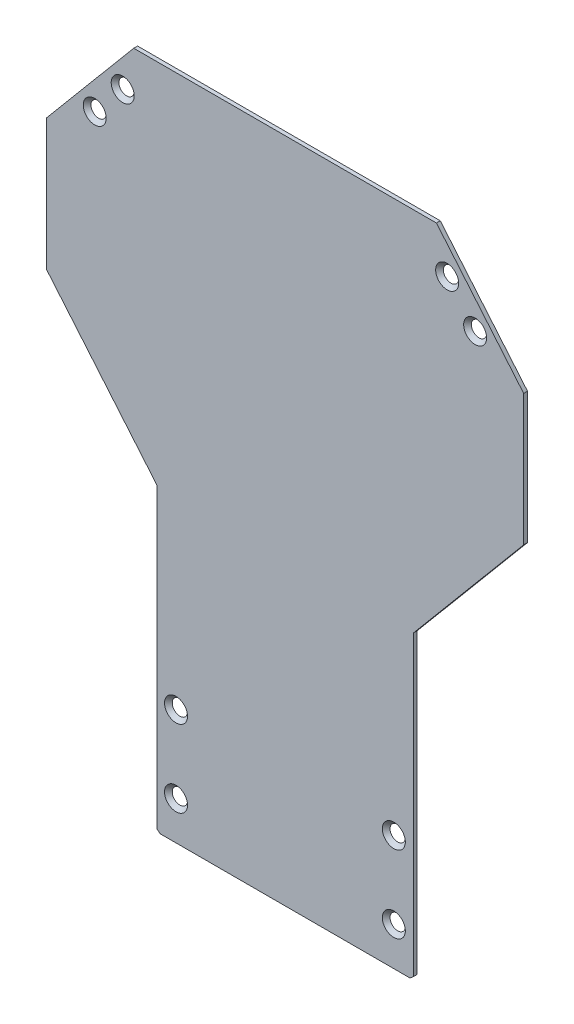
from build123d import *

# Parameters (mm, degrees)
RESSALTO_EXTRUS_O1_DEPTH                     = 1.5
ESCAREADO_PARA_PARAFUSO_ALLEN_SEXTAV_2_COUNT = 2
ESCAREADO_PARA_PARAFUSO_ALLEN_SEXTAV_2_PITCH = 16.970294761
ESCAREADO_PARA_PARAFUSO_ALLEN_SEXTAV_3_COUNT = 2
ESCAREADO_PARA_PARAFUSO_ALLEN_SEXTAV_3_PITCH = 126.454837383
ESCAREADO_PARA_PARAFUSO_ALLEN_SEXTAV_4_COUNT = 2
ESCAREADO_PARA_PARAFUSO_ALLEN_SEXTAV_4_PITCH = 137.976919064
ESCAREADO_PARA_PARAFUSO_ALLEN_SEXTAV_5_COUNT = 2
ESCAREADO_PARA_PARAFUSO_ALLEN_SEXTAV_5_PITCH = 225.316554427
ESCAREADO_PARA_PARAFUSO_ALLEN_SEXTAV_6_COUNT = 2
ESCAREADO_PARA_PARAFUSO_ALLEN_SEXTAV_6_PITCH = 252.205372066
ESCAREADO_PARA_PARAFUSO_ALLEN_SEXTAV_7_COUNT = 2
ESCAREADO_PARA_PARAFUSO_ALLEN_SEXTAV_7_PITCH = 229.941146022
ESCAREADO_PARA_PARAFUSO_ALLEN_SEXTAV_8_COUNT = 2
ESCAREADO_PARA_PARAFUSO_ALLEN_SEXTAV_8_PITCH = 200.082309648


with BuildPart() as part:
    # Esboço1 → Ressalto-extrusão1 (new body)
    with BuildSketch(Plane.XY):
        Polygon((59.050720106, 130.399321825), (-58.939675618, 130.399321825), (-92.944477756, 89.873976712), (-92.944477756, 38.765530101), (-49.944477756, -12.47987438), (-49.944477756, -128.492963544), (-48.624354865, -129.600678175), (48.735399354, -129.600678175), (50.055522244, -128.492963544), (50.055522244, -12.47987438), (93.055522244, 38.765530101), (93.055522244, 89.873976712), align=None)
    extrude(amount=RESSALTO_EXTRUS_O1_DEPTH)

    # Esboço4 → Escareado para parafuso Allen sextavado escareado de M41 (revolve, cut)
    with BuildSketch(Plane(origin=(-63.227418691, 114.399321825, 1.5), x_dir=(0, -1, 0), z_dir=(1, 0, 0))):
        Polygon((0, 0), (0, 1.5), (2.25, 1.5), (2.25, 2.23), (4.48, 0), align=None)
    escareado_para_parafuso_allen_sextavado = revolve(axis=Axis((-63.227418691, 114.399321825, 7.85), (0, 0, -1)), mode=Mode.SUBTRACT)

    # Escareado para parafuso Allen sextav 2: Escareado para parafuso Allen sextavado escareado de M41 ×2
    with Locations(*[Vector(-0.64278761, -0.766044443, 0) * (i * ESCAREADO_PARA_PARAFUSO_ALLEN_SEXTAV_2_PITCH) for i in range(1, ESCAREADO_PARA_PARAFUSO_ALLEN_SEXTAV_2_COUNT)]):
        add(escareado_para_parafuso_allen_sextavado, mode=Mode.SUBTRACT)

    # Escareado para parafuso Allen sextav 3: Escareado para parafuso Allen sextavado escareado de M41 ×2
    with Locations(*[(i * ESCAREADO_PARA_PARAFUSO_ALLEN_SEXTAV_3_PITCH, 0, 0) for i in range(1, ESCAREADO_PARA_PARAFUSO_ALLEN_SEXTAV_3_COUNT)]):
        add(escareado_para_parafuso_allen_sextavado, mode=Mode.SUBTRACT)

    # Escareado para parafuso Allen sextav 4: Escareado para parafuso Allen sextavado escareado de M41 ×2
    with Locations(*[Vector(0.995551528, -0.094218657, 0) * (i * ESCAREADO_PARA_PARAFUSO_ALLEN_SEXTAV_4_PITCH) for i in range(1, ESCAREADO_PARA_PARAFUSO_ALLEN_SEXTAV_4_COUNT)]):
        add(escareado_para_parafuso_allen_sextavado, mode=Mode.SUBTRACT)

    # Escareado para parafuso Allen sextav 5: Escareado para parafuso Allen sextavado escareado de M41 ×2
    with Locations(*[Vector(0.468993043, -0.88320186, 0) * (i * ESCAREADO_PARA_PARAFUSO_ALLEN_SEXTAV_5_PITCH) for i in range(1, ESCAREADO_PARA_PARAFUSO_ALLEN_SEXTAV_5_COUNT)]):
        add(escareado_para_parafuso_allen_sextavado, mode=Mode.SUBTRACT)

    # Escareado para parafuso Allen sextav 6: Escareado para parafuso Allen sextavado escareado de M41 ×2
    with Locations(*[Vector(0.418991458, -0.907990175, 0) * (i * ESCAREADO_PARA_PARAFUSO_ALLEN_SEXTAV_6_PITCH) for i in range(1, ESCAREADO_PARA_PARAFUSO_ALLEN_SEXTAV_6_COUNT)]):
        add(escareado_para_parafuso_allen_sextavado, mode=Mode.SUBTRACT)

    # Escareado para parafuso Allen sextav 7: Escareado para parafuso Allen sextavado escareado de M41 ×2
    with Locations(*[Vector(0.090383741, -0.995907013, 0) * (i * ESCAREADO_PARA_PARAFUSO_ALLEN_SEXTAV_7_PITCH) for i in range(1, ESCAREADO_PARA_PARAFUSO_ALLEN_SEXTAV_7_COUNT)]):
        add(escareado_para_parafuso_allen_sextavado, mode=Mode.SUBTRACT)

    # Escareado para parafuso Allen sextav 8: Escareado para parafuso Allen sextavado escareado de M41 ×2
    with Locations(*[Vector(0.103871956, -0.994590678, 0) * (i * ESCAREADO_PARA_PARAFUSO_ALLEN_SEXTAV_8_PITCH) for i in range(1, ESCAREADO_PARA_PARAFUSO_ALLEN_SEXTAV_8_COUNT)]):
        add(escareado_para_parafuso_allen_sextavado, mode=Mode.SUBTRACT)


solid = part.part
